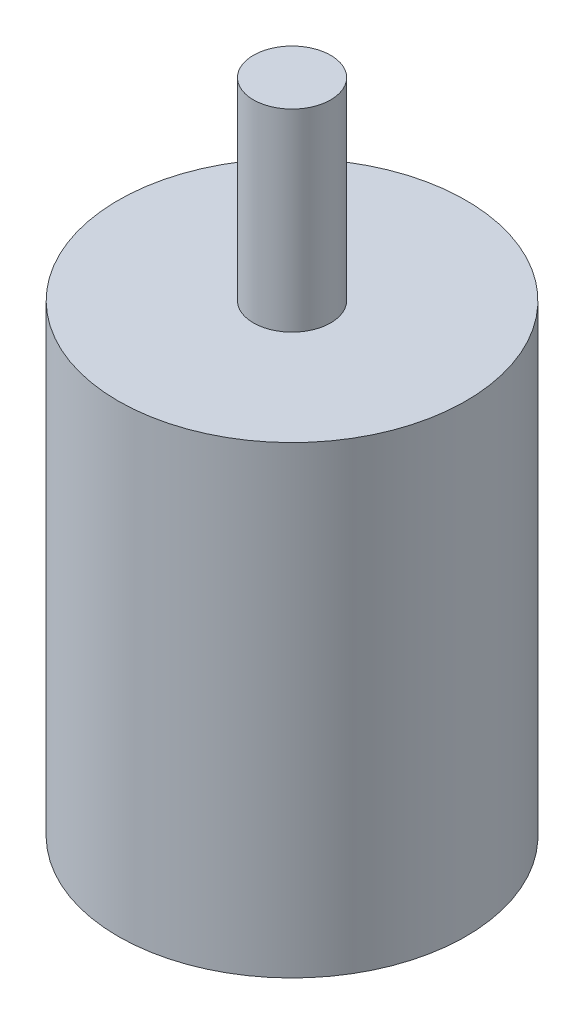
from build123d import *

# Parameters (mm, degrees)
SKETCH1_R           = 22.5
BOSS_EXTRUDE1_DEPTH = 60
SKETCH2_R           = 5
BOSS_EXTRUDE2_DEPTH = 25


with BuildPart() as part:
    # Sketch1 → Boss-Extrude1 (new body)
    with BuildSketch(Plane(origin=(0, 0, 0), x_dir=(1, 0, 0), z_dir=(0, 1, 0))):
        Circle(SKETCH1_R)
    extrude(amount=BOSS_EXTRUDE1_DEPTH)

    # Sketch2 → Boss-Extrude2 (add)
    with BuildSketch(Plane(origin=(0, 60, 0), x_dir=(1, 0, 0), z_dir=(0, 1, 0))):
        Circle(SKETCH2_R)
    extrude(amount=BOSS_EXTRUDE2_DEPTH)


solid = part.part
